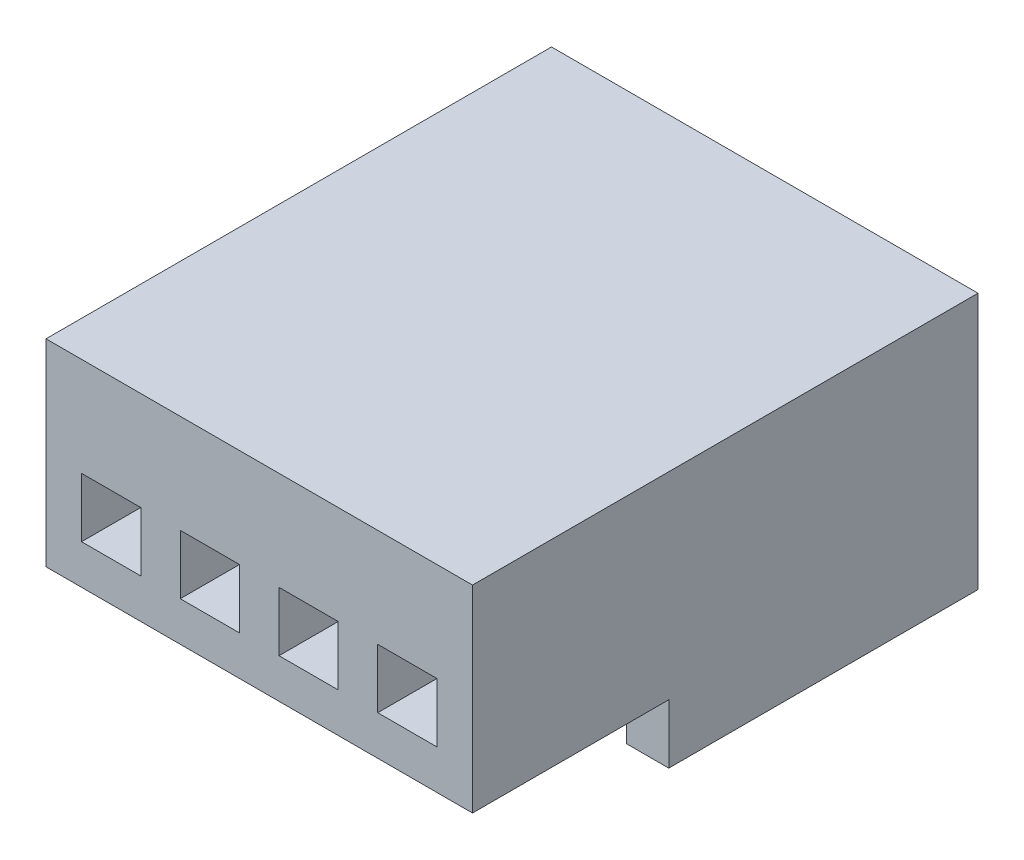
from build123d import *

# Parameters (mm, degrees)
SKETCH_1_W          = 10.8
SKETCH_1_H          = 12.8
EXTRUDE_1_DEPTH     = 5
SKETCH_2_W          = 1.5
SKETCH_2_H          = 1.5
CUT_EXTRUDE_1_DEPTH = 13.8
SKETCH_3_W          = 0.979411712
SKETCH_3_H          = 7.830694271
SKETCH_3_W_2        = 1.065082028
EXTRUDE_2_DEPTH     = 1.5


with BuildPart() as part:
    # 草圖1 → 填料-伸長1 (new body)
    with BuildSketch(Plane(origin=(0, 0, 0), x_dir=(1, 0, 0), z_dir=(0, 1, 0))):
        with Locations((0, 6.4)):
            Rectangle(SKETCH_1_W, SKETCH_1_H)
    extrude(amount=EXTRUDE_1_DEPTH)

    # 草圖2 → 除料-伸長1 (cut, through all)
    with BuildSketch(Plane(origin=(0, 0, -12.8), x_dir=(-1, 0, 0), z_dir=(0, 0, -1))):
        with Locations((-3.75, 1.75)):
            Rectangle(SKETCH_2_W, SKETCH_2_H)
        with Locations((-1.25, 1.75)):
            Rectangle(SKETCH_2_W, SKETCH_2_H)
        with Locations((1.25, 1.75)):
            Rectangle(SKETCH_2_W, SKETCH_2_H)
        with Locations((3.75, 1.75)):
            Rectangle(SKETCH_2_W, SKETCH_2_H)
    extrude(amount=-CUT_EXTRUDE_1_DEPTH, mode=Mode.SUBTRACT)

    # 草圖3 → 填料-伸長2 (add)
    with BuildSketch(Plane.XZ):
        with Locations((-4.910294144, -8.884652865)):
            Rectangle(SKETCH_3_W, SKETCH_3_H)
        with Locations((4.867458986, -8.884652865)):
            Rectangle(SKETCH_3_W_2, SKETCH_3_H)
    extrude(amount=EXTRUDE_2_DEPTH)


solid = part.part
